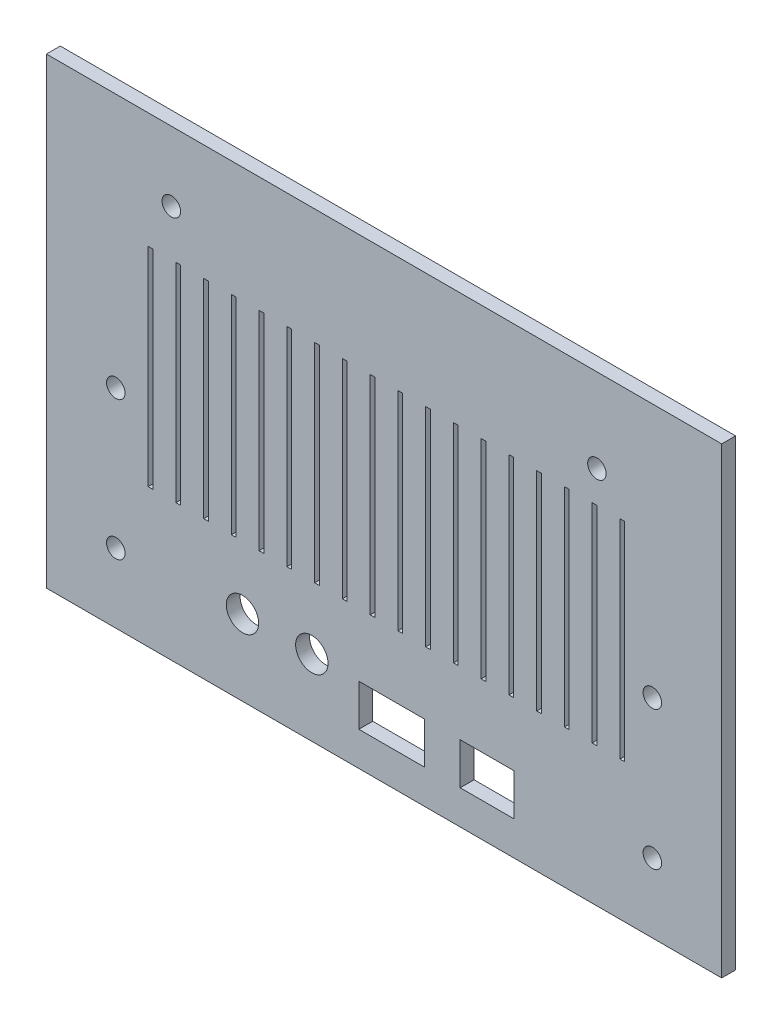
from build123d import *

# Parameters (mm, degrees)
SKETCH1_W           = 146
SKETCH1_H           = 100
BOSS_EXTRUDE1_DEPTH = 3
SKETCH2_W           = 1
SKETCH2_H           = 45
CUT_EXTRUDE1_DEPTH  = 4
SKETCH3_R           = 2
CUT_EXTRUDE2_DEPTH  = 4
SKETCH4_W           = 11.62
SKETCH4_H           = 9
CUT_EXTRUDE3_DEPTH  = 4
SKETCH5_W           = 14.16
SKETCH5_H           = 9
CUT_EXTRUDE4_DEPTH  = 4
SKETCH6_R           = 3.5
CUT_EXTRUDE5_DEPTH  = 4
SKETCH8_R           = 2
CUT_EXTRUDE6_DEPTH  = 4
SKETCH9_R           = 2
CUT_EXTRUDE7_DEPTH  = 4


with BuildPart() as part:
    # Sketch1 → Boss-Extrude1 (new body)
    with BuildSketch(Plane.XY):
        with Locations((24.755849622, 29.633412311)):
            Rectangle(SKETCH1_W, SKETCH1_H)
    extrude(amount=BOSS_EXTRUDE1_DEPTH)

    # Sketch2 → Cut-Extrude1 (cut, through all)
    with BuildSketch(Plane.XY.offset(3)):
        with Locations((-19.744150378, 32.133412311)):
            Rectangle(SKETCH2_W, SKETCH2_H)
        with Locations((-25.744150378, 32.133412311)):
            Rectangle(SKETCH2_W, SKETCH2_H)
        with Locations((-13.744150378, 32.133412311)):
            Rectangle(SKETCH2_W, SKETCH2_H)
        with Locations((-7.744150378, 32.133412311)):
            Rectangle(SKETCH2_W, SKETCH2_H)
        with Locations((-1.744150378, 32.133412311)):
            Rectangle(SKETCH2_W, SKETCH2_H)
        with Locations((4.255849622, 32.133412311)):
            Rectangle(SKETCH2_W, SKETCH2_H)
        with Locations((10.255849622, 32.133412311)):
            Rectangle(SKETCH2_W, SKETCH2_H)
        with Locations((16.255849622, 32.133412311)):
            Rectangle(SKETCH2_W, SKETCH2_H)
        with Locations((22.255849622, 32.133412311)):
            Rectangle(SKETCH2_W, SKETCH2_H)
        with Locations((34.255849622, 32.133412311)):
            Rectangle(SKETCH2_W, SKETCH2_H)
        with Locations((28.255849622, 32.133412311)):
            Rectangle(SKETCH2_W, SKETCH2_H)
        with Locations((40.255849622, 32.133412311)):
            Rectangle(SKETCH2_W, SKETCH2_H)
        with Locations((46.255849622, 32.133412311)):
            Rectangle(SKETCH2_W, SKETCH2_H)
        with Locations((52.255849622, 32.133412311)):
            Rectangle(SKETCH2_W, SKETCH2_H)
        with Locations((58.255849622, 32.133412311)):
            Rectangle(SKETCH2_W, SKETCH2_H)
        with Locations((64.255849622, 32.133412311)):
            Rectangle(SKETCH2_W, SKETCH2_H)
        with Locations((70.255849622, 32.133412311)):
            Rectangle(SKETCH2_W, SKETCH2_H)
        with Locations((76.255849622, 32.133412311)):
            Rectangle(SKETCH2_W, SKETCH2_H)
    extrude(amount=-CUT_EXTRUDE1_DEPTH, mode=Mode.SUBTRACT)

    # Sketch3 → Cut-Extrude2 (cut, through all)
    with BuildSketch(Plane.XY.offset(3)):
        with Locations((-33.244150378, -5.366587689)):
            Circle(SKETCH3_R)
        with Locations((82.755849622, -5.366587689)):
            Circle(SKETCH3_R)
    extrude(amount=-CUT_EXTRUDE2_DEPTH, mode=Mode.SUBTRACT)

    # Sketch4 → Cut-Extrude3 (cut, through all)
    with BuildSketch(Plane(origin=(0, 0, 0), x_dir=(-1, 0, 0), z_dir=(0, 0, -1))):
        with Locations((-47.025849622, -8.521305626)):
            Rectangle(SKETCH4_W, SKETCH4_H)
    extrude(amount=-CUT_EXTRUDE3_DEPTH, mode=Mode.SUBTRACT)

    # Sketch5 → Cut-Extrude4 (cut, through all)
    with BuildSketch(Plane.XY.offset(3)):
        with Locations((26.385849622, -8.521305626)):
            Rectangle(SKETCH5_W, SKETCH5_H)
    extrude(amount=-CUT_EXTRUDE4_DEPTH, mode=Mode.SUBTRACT)

    # Sketch6 → Cut-Extrude5 (cut, through all)
    with BuildSketch(Plane(origin=(0, 0, 0), x_dir=(-1, 0, 0), z_dir=(0, 0, -1))):
        with Locations((-9.139177798, -4.021305626)):
            Circle(SKETCH6_R)
        with Locations((5.860822202, -4.021305626)):
            Circle(SKETCH6_R)
    extrude(amount=-CUT_EXTRUDE5_DEPTH, mode=Mode.SUBTRACT)

    # Sketch8 → Cut-Extrude6 (cut, through all)
    with BuildSketch(Plane.XY.offset(3)):
        with Locations((82.755849622, 24.633412311)):
            Circle(SKETCH8_R)
        with Locations((-33.244150378, 24.633412311)):
            Circle(SKETCH8_R)
    extrude(amount=-CUT_EXTRUDE6_DEPTH, mode=Mode.SUBTRACT)

    # Sketch9 → Cut-Extrude7 (cut, through all)
    with BuildSketch(Plane.XY.offset(3)):
        with Locations((-21.244150378, 64.633412311)):
            Circle(SKETCH9_R)
        with Locations((70.77306316, 61.532054099)):
            Circle(SKETCH9_R)
    extrude(amount=-CUT_EXTRUDE7_DEPTH, mode=Mode.SUBTRACT)


solid = part.part
